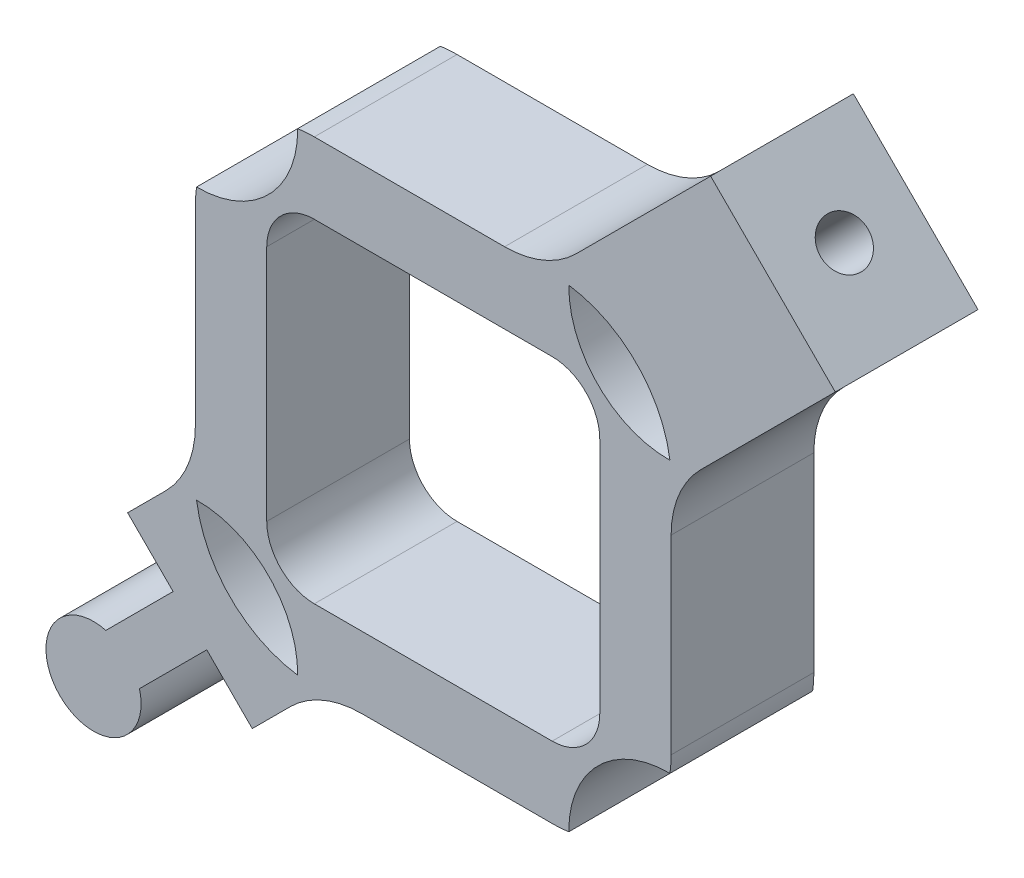
from build123d import *

# Parameters (mm, degrees)
EXTRUDE_1_DEPTH     = 3
SKETCH_4_W          = 3
SKETCH_4_H          = 3.704951288
EXTRUDE_3_DEPTH     = 1
CUT_EXTRUDE_2_REACH = 25.05
SKETCH_6_R          = 0.5
CUT_EXTRUDE_1_DEPTH = 3


with BuildPart() as part:
    # 草图1 → 凸台-拉伸1 (new body)
    with BuildSketch(Plane.XY):
        with BuildLine():
            ThreePointArc((-4.975392322, 2.84990406), (-4.993840493, 2.675384142), (-5, 2.5))
            Line((-5, 2.5), (-5, -1.5))
            Line((-5, -1.5), (-5, -2.5))
            ThreePointArc((-5, -2.5), (-4.993840493, -2.675384142), (-4.975392322, -2.84990406))
            ThreePointArc((-4.975392322, -2.84990406), (-3.464823228, -3.464823228), (-2.84990406, -4.975392322))
            ThreePointArc((-2.84990406, -4.975392322), (-2.675384142, -4.993840493), (-2.5, -5))
            Line((-2.5, -5), (-1.5, -5))
            Line((-1.5, -5), (2.5, -5))
            ThreePointArc((2.5, -5), (2.675384142, -4.993840493), (2.84990406, -4.975392322))
            ThreePointArc((2.84990406, -4.975392322), (3.464823228, -3.464823228), (4.975392322, -2.84990406))
            ThreePointArc((4.975392322, -2.84990406), (4.993840493, -2.675384142), (5, -2.5))
            Line((5, -2.5), (5, 1.5))
            Line((5, 1.5), (5, 2.5))
            ThreePointArc((5, 2.5), (4.993840493, 2.675384142), (4.975392322, 2.84990406))
            ThreePointArc((4.975392322, 2.84990406), (3.464823228, 3.464823228), (2.84990406, 4.975392322))
            ThreePointArc((2.84990406, 4.975392322), (2.675384142, 4.993840493), (2.5, 5))
            Line((2.5, 5), (1.5, 5))
            Line((1.5, 5), (-2.5, 5))
            ThreePointArc((-2.5, 5), (-2.675384142, 4.993840493), (-2.84990406, 4.975392322))
            ThreePointArc((-2.84990406, 4.975392322), (-3.464823228, 3.464823228), (-4.975392322, 2.84990406))
        make_face()
        with BuildLine():
            ThreePointArc((-3.5, 2.5), (-3.207106781, 3.207106781), (-2.5, 3.5))
            Line((-2.5, 3.5), (2.5, 3.5))
            ThreePointArc((2.5, 3.5), (3.207106781, 3.207106781), (3.5, 2.5))
            Line((3.5, 2.5), (3.5, -2.5))
            ThreePointArc((3.5, -2.5), (3.207106781, -3.207106781), (2.5, -3.5))
            Line((2.5, -3.5), (-2.5, -3.5))
            ThreePointArc((-2.5, -3.5), (-3.207106781, -3.207106781), (-3.5, -2.5))
            Line((-3.5, -2.5), (-3.5, 2.5))
        make_face(mode=Mode.SUBTRACT)
        with BuildLine():
            Line((-5, -2.5), (-5, -1.5))
            ThreePointArc((-5, -1.5), (-5.161755993, -2.313202294), (-5.62239809, -3.00260191))
            Line((-5.62239809, -3.00260191), (-8.450825215, -5.831029035))
            Line((-8.450825215, -5.831029035), (-5.831029035, -8.450825215))
            Line((-5.831029035, -8.450825215), (-3.00260191, -5.62239809))
            ThreePointArc((-3.00260191, -5.62239809), (-2.313202294, -5.161755993), (-1.5, -5))
            Line((-1.5, -5), (-2.5, -5))
            ThreePointArc((-2.5, -5), (-2.675384142, -4.993840493), (-2.84990406, -4.975392322))
            ThreePointArc((-2.84990406, -4.975392322), (-4.267766953, -4.267766953), (-4.975392322, -2.84990406))
            ThreePointArc((-4.975392322, -2.84990406), (-4.993840493, -2.675384142), (-5, -2.5))
        make_face()
        with BuildLine():
            ThreePointArc((3.00260191, 5.62239809), (2.313202294, 5.161755993), (1.5, 5))
            Line((1.5, 5), (2.5, 5))
            ThreePointArc((2.5, 5), (2.675384142, 4.993840493), (2.84990406, 4.975392322))
            ThreePointArc((2.84990406, 4.975392322), (4.267766953, 4.267766953), (4.975392322, 2.84990406))
            ThreePointArc((4.975392322, 2.84990406), (4.993840493, 2.675384142), (5, 2.5))
            Line((5, 2.5), (5, 1.5))
            ThreePointArc((5, 1.5), (5.161755993, 2.313202294), (5.62239809, 3.00260191))
            Line((5.62239809, 3.00260191), (8.450825215, 5.831029035))
            Line((8.450825215, 5.831029035), (5.831029035, 8.450825215))
            Line((5.831029035, 8.450825215), (3.00260191, 5.62239809))
        make_face()
    extrude(amount=EXTRUDE_1_DEPTH)

    # 草图4 → 凸台-拉伸3 (add)
    with BuildSketch(Plane(origin=(-7.140927125, -7.140927125, 0), x_dir=(0, 0, 1), z_dir=(-0.707106781, -0.707106781, 0))):
        with Locations((1.5, 0)):
            Rectangle(SKETCH_4_W, SKETCH_4_H)
    extrude(amount=EXTRUDE_3_DEPTH)

    # 草图6 → 切除-拉伸2 (cut, up to next)
    with BuildSketch(Plane(origin=(7.140927125, 7.140927125, 0), x_dir=(0, 0, -1), z_dir=(0.707106781, 0.707106781, 0)), mode=Mode.PRIVATE) as cut_extrude_2_sk1:
        with Locations((-1.5, 0)):
            Circle(SKETCH_6_R)
    cut_extrude_2_tool1 = extrude(cut_extrude_2_sk1.sketch, amount=-CUT_EXTRUDE_2_REACH, mode=Mode.PRIVATE) & part.part
    add(cut_extrude_2_tool1.solids().sort_by_distance((7.140927, 7.140927, 1.5))[0], mode=Mode.SUBTRACT)

    # 草图5 → 切除-拉伸1 (cut)
    with BuildSketch(Plane.XY.offset(3)):
        with BuildLine():
            Line((-6.88210808, -6.175001298), (-5.467894517, -4.760787736))
            Line((-5.467894517, -4.760787736), (-6.424239217, -3.804443037))
            Line((-6.424239217, -3.804443037), (-9.157931996, -6.538135816))
            Line((-9.157931996, -6.538135816), (-7.848033901, -7.848033911))
            ThreePointArc((-7.848033901, -7.848033911), (-8.00695253, -6.640927128), (-6.88210808, -6.175001298))
        make_face()
        with BuildLine():
            Line((-3.804443037, -6.424239217), (-4.760787736, -5.467894517))
            Line((-4.760787736, -5.467894517), (-6.175001298, -6.88210808))
            ThreePointArc((-6.175001298, -6.88210808), (-6.149482263, -7.010400933), (-6.140927125, -7.140927125))
            ThreePointArc((-6.140927125, -7.140927125), (-6.758243689, -8.064806656), (-7.848033901, -7.848033911))
            Line((-7.848033901, -7.848033911), (-6.538135816, -9.157931996))
            Line((-6.538135816, -9.157931996), (-3.804443037, -6.424239217))
        make_face()
    extrude(amount=-CUT_EXTRUDE_1_DEPTH, mode=Mode.SUBTRACT)


solid = part.part
